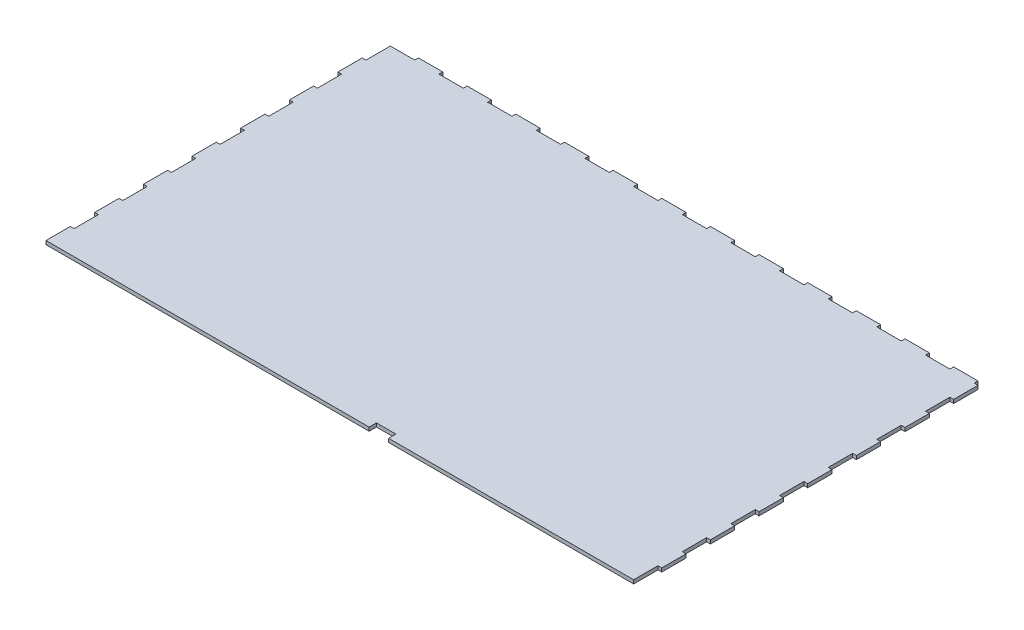
from build123d import *

# Parameters (mm, degrees)
SALIENTE_EXTRUIR1_DEPTH = 3
CROQUIS2_W              = 16.03671643
CROQUIS2_H              = 6
CORTAR_EXTRUIR1_DEPTH   = 10


with BuildPart() as part:
    # Croquis1 → Saliente-Extruir1 (new body)
    with BuildSketch(Plane(origin=(0, 0, 0), x_dir=(1, 0, 0), z_dir=(0, 1, 0))):
        Polygon((480, 280), (480, 283.1), (460, 283.1), (460, 280), (440, 280), (440, 283.1), (420, 283.1), (420, 280), (400, 280), (400, 283.1), (380, 283.1), (380, 280), (360, 280), (360, 283.1), (340, 283.1), (340, 280), (320, 280), (320, 283.1), (300, 283.1), (300, 280), (280, 280), (280, 283.1), (260, 283.1), (260, 280), (240, 280), (240, 283.1), (220, 283.1), (220, 280), (200, 280), (200, 283.1), (180, 283.1), (180, 280), (160, 280), (160, 283.1), (140, 283.1), (140, 280), (120, 280), (120, 283.1), (100, 283.1), (100, 280), (80, 280), (80, 283.1), (60, 283.1), (60, 280), (40, 280), (40, 283.1), (20, 283.1), (20, 280), (0, 280), (0, 260), (-3.1, 260), (-3.1, 240), (0, 240), (0, 220), (-3.1, 220), (-3.1, 200), (0, 200), (0, 180), (-3.1, 180), (-3.1, 160), (0, 160), (0, 140), (-3.1, 140), (-3.1, 120), (0, 120), (0, 100), (-3.1, 100), (-3.1, 80), (0, 80), (0, 60), (-3.1, 60), (-3.1, 40), (0, 40), (0, 20), (-3.1, 20), (-3.1, 0), (0, 0), (480, 0), (480, 20), (483.1, 20), (483.1, 40), (480, 40), (480, 60), (483.1, 60), (483.1, 80), (480, 80), (480, 100), (483.1, 100), (483.1, 120), (480, 120), (480, 140), (483.1, 140), (483.1, 160), (480, 160), (480, 180), (483.1, 180), (483.1, 200), (480, 200), (480, 220), (483.1, 220), (483.1, 240), (480, 240), (480, 260), (483.1, 260), (483.1, 280), align=None)
    extrude(amount=SALIENTE_EXTRUIR1_DEPTH)

    # Croquis2 → Cortar-Extruir1 (cut)
    with BuildSketch(Plane(origin=(0, 3, 0), x_dir=(1, 0, 0), z_dir=(0, 1, 0))):
        with Locations((270.581641785, 3)):
            Rectangle(CROQUIS2_W, CROQUIS2_H)
    extrude(amount=-CORTAR_EXTRUIR1_DEPTH, mode=Mode.SUBTRACT)


solid = part.part
